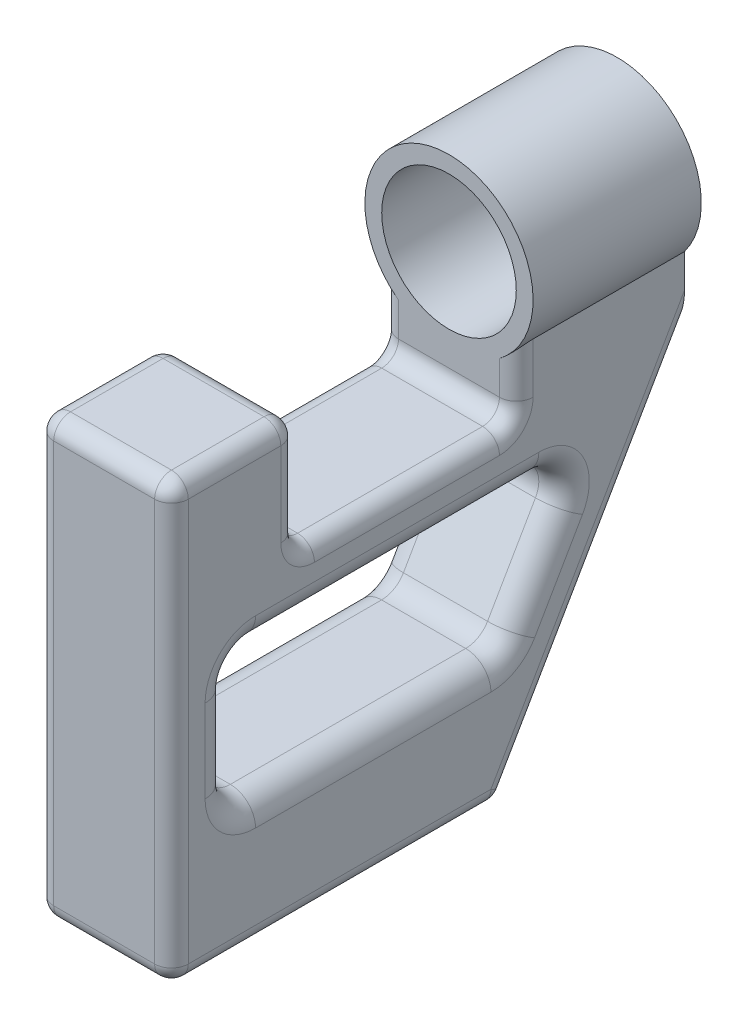
from build123d import *

# Parameters (mm, degrees)
SCHIZZO1_R                        = 10
ESTRUSIONE_ESTRUSIONE1_DEPTH      = 20
ESTRUSIONE_ESTRUSIONE2_DEPTH      = 8
ESTRUSIONE_ESTRUSIONE2_DEPTH_BACK = 8
SCHIZZO3_R                        = 8
TAGLIO_ESTRUSIONE1_DEPTH          = 20
SCHIZZO4_R                        = 3.75
TAGLIO_ESTRUSIONE2_DEPTH          = 8
RACCORDO1_R                       = 2
TAGLIO_ESTRUSIONE4_REACH          = 20
RACCORDO4_R                       = 3


with BuildPart() as part:
    # Schizzo1 → Estrusione-Estrusione1 (new body)
    with BuildSketch(Plane.XY):
        Circle(SCHIZZO1_R)
    extrude(amount=ESTRUSIONE_ESTRUSIONE1_DEPTH)

    # Schizzo2 → Estrusione-Estrusione2 (add, two sides)
    with BuildSketch(Plane(origin=(0, 0, 0), x_dir=(0, 0, -1), z_dir=(1, 0, 0))) as estrusione_estrusione2_sk:
        Polygon((0, 0), (-20, 0), (-20, -14), (-46, -14), (-46, 0), (-61, 0), (-61, -51.86222015), (-21.859762995, -51.86222015), (0, -14), align=None)
    extrude(amount=ESTRUSIONE_ESTRUSIONE2_DEPTH)
    extrude(estrusione_estrusione2_sk.sketch, amount=-ESTRUSIONE_ESTRUSIONE2_DEPTH_BACK)

    # Schizzo3 → Taglio-Estrusione1 (cut)
    with BuildSketch(Plane(origin=(0, 0, 0), x_dir=(-1, 0, 0), z_dir=(0, 0, -1))):
        Circle(SCHIZZO3_R)
    extrude(amount=-TAGLIO_ESTRUSIONE1_DEPTH, mode=Mode.SUBTRACT)

    # Schizzo4 → Taglio-Estrusione2 (cut)
    with BuildSketch(Plane.XZ.offset(51.86222015)):
        with Locations((0, 38)):
            Circle(SCHIZZO4_R)
    extrude(amount=-TAGLIO_ESTRUSIONE2_DEPTH, mode=Mode.SUBTRACT)

    # Raccordo1
    raccordo1_edges = [part.edges().sort_by_distance(p)[0] for p in [
        (8, -10, 20),
        (8, -14, 33),
        (8, -7, 46),
        (8, 0, 53.5),
        (8, -25.931110075, 61),
        (8, -51.86222015, 41.429881498),
        (8, -32.931110075, 10.929881498),
        (0, -14, 0),
        (-8, -32.931110075, 10.929881498),
        (0, -51.86222015, 21.859762995),
        (-8, -51.86222015, 41.429881498),
        (0, -51.86222015, 61),
        (-8, -25.931110075, 61),
        (0, 0, 61),
        (-8, 0, 53.5),
        (0, 0, 46),
        (-8, -7, 46),
        (0, -14, 46),
        (-8, -14, 33),
        (-8, -10, 20),
        (0, -14, 20),
        (-3.75, -51.86222015, 38),
    ]]
    fillet(raccordo1_edges, radius=RACCORDO1_R)

    # Schizzo6 → Taglio-Estrusione4 (cut, up to next)
    with BuildSketch(Plane(origin=(8, 0, 0), x_dir=(0, 0, -1), z_dir=(1, 0, 0)), mode=Mode.PRIVATE) as taglio_estrusione4_sk1:
        Polygon((-54, -21), (-12.124355653, -21), (-21.282412726, -36.86222015), (-54, -36.86222015), align=None)
    taglio_estrusione4_tool1 = extrude(taglio_estrusione4_sk1.sketch, amount=-TAGLIO_ESTRUSIONE4_REACH, mode=Mode.PRIVATE) & part.part
    add(taglio_estrusione4_tool1.solids().sort_by_distance((8, -28.606534, 35.257995))[0], mode=Mode.SUBTRACT)

    # Raccordo4
    raccordo4_edges = [part.edges().sort_by_distance(p)[0] for p in [
        (0, -36.86222015, 54),
        (0, -21, 54),
        (0, -21, 12.124355653),
        (0, -36.86222015, 21.282412726),
        (8, -28.931110075, 54),
        (8, -36.86222015, 37.641206363),
        (8, -28.931110075, 16.70338419),
        (8, -21, 33.062177826),
        (-8, -36.86222015, 37.641206363),
        (-8, -28.931110075, 54),
        (-8, -21, 33.062177826),
        (-8, -28.931110075, 16.70338419),
    ]]
    fillet(raccordo4_edges, radius=RACCORDO4_R)


solid = part.part
